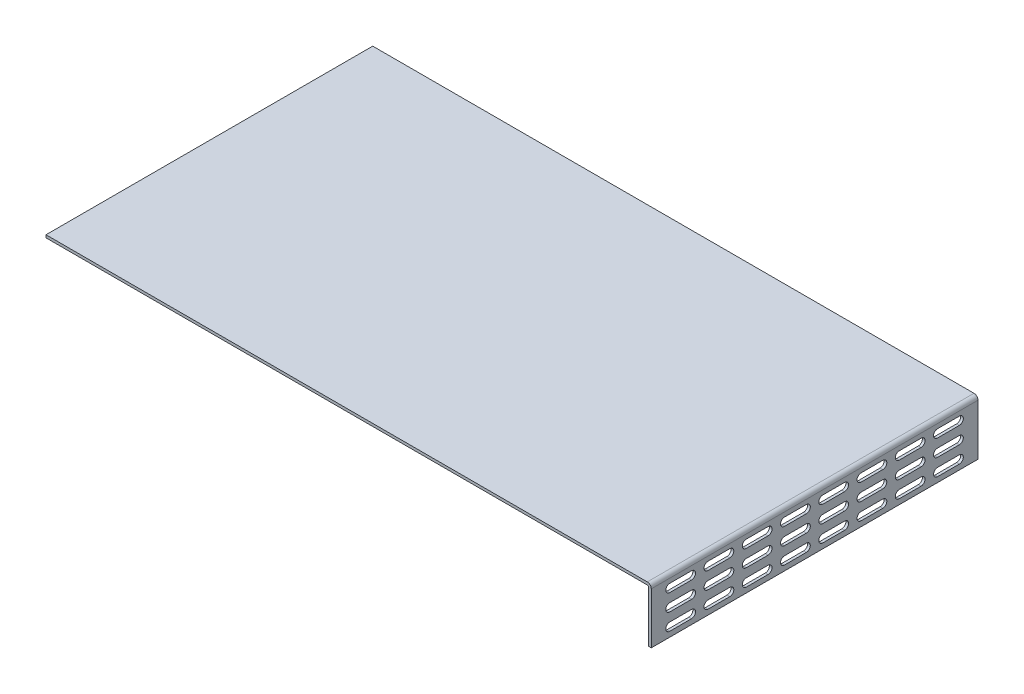
from build123d import *

# Parameters (mm, degrees)
BOSS_EXTRUDE1_DEPTH  = 60.198
FILLET1_R            = 0.4826
FILLET2_R            = 1.4732
CUT_EXTRUDE1_DEPTH   = 0.9906
LPATTERN1_COUNT      = 3
LPATTERN1_PITCH      = 6.1722
LPATTERN1_COUNT_DIR2 = 8
LPATTERN1_PITCH_DIR2 = 14.097


with BuildPart() as part:
    # Sketch1 → Boss-Extrude1 (new body, symmetric)
    with BuildSketch(Plane.XY):
        Polygon((0, 0), (0, 20.32), (-223.04375, 20.32), (-223.04375, 19.3294), (-0.9906, 19.3294), (-0.9906, 0), align=None)
    extrude(amount=BOSS_EXTRUDE1_DEPTH, both=True)

    # Fillet1
    fillet1_edges = [part.edges().sort_by_distance(p)[0] for p in [
        (-0.9906, 19.3294, 0),
    ]]
    fillet(fillet1_edges, radius=FILLET1_R)

    # Fillet2
    fillet2_edges = [part.edges().sort_by_distance(p)[0] for p in [
        (0, 20.32, 0),
    ]]
    fillet(fillet2_edges, radius=FILLET2_R)

    # Sketch2 → Cut-Extrude1 (cut)
    with BuildSketch(Plane(origin=(0, 0, 0), x_dir=(0, 0, -1), z_dir=(1, 0, 0))):
        with BuildLine():
            Line((-53.3908, 4.8514), (-45.3644, 4.8514))
            ThreePointArc((-45.3644, 4.8514), (-43.8912, 3.3782), (-45.3644, 1.905))
            Line((-45.3644, 1.905), (-53.3908, 1.905))
            ThreePointArc((-53.3908, 1.905), (-54.864, 3.3782), (-53.3908, 4.8514))
        make_face()
    cut_extrude1 = extrude(amount=-CUT_EXTRUDE1_DEPTH, mode=Mode.SUBTRACT)

    # LPattern1: Cut-Extrude1 3 × 8
    with Locations(*[(0, i * LPATTERN1_PITCH, -j * LPATTERN1_PITCH_DIR2) for i in range(LPATTERN1_COUNT) for j in range(LPATTERN1_COUNT_DIR2) if (i, j) != (0, 0)]):
        add(cut_extrude1, mode=Mode.SUBTRACT)


solid = part.part
